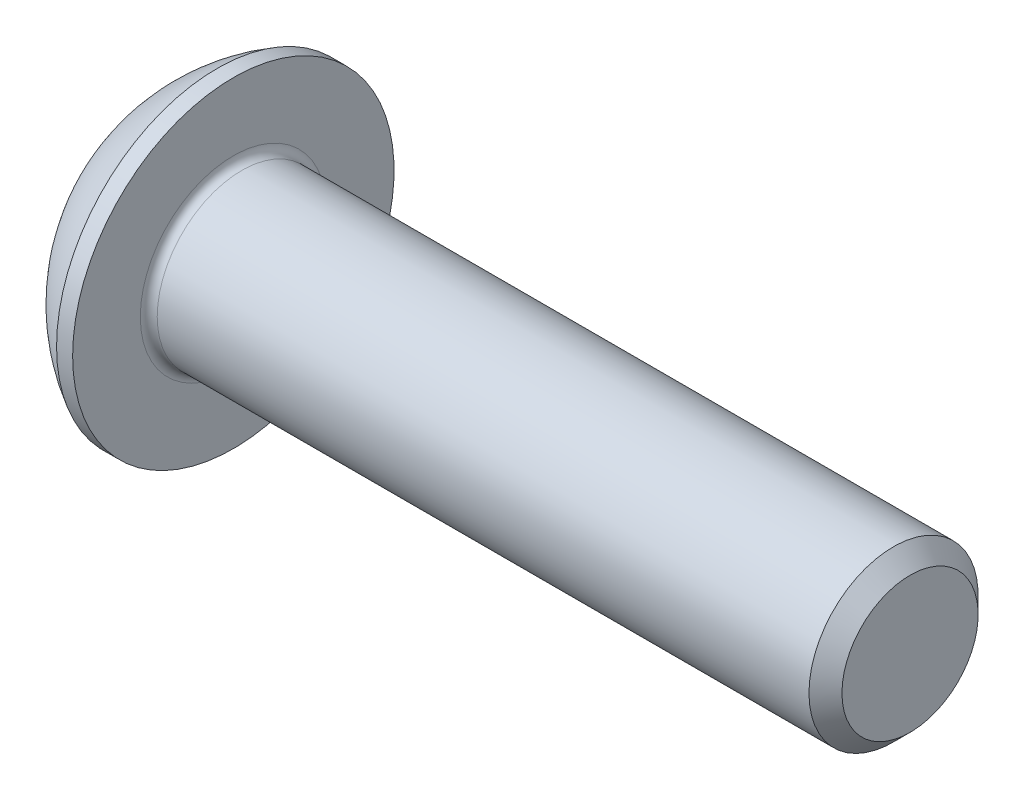
from build123d import *

# Parameters (mm, degrees)
FILLET1_R   = 0.2
HEX_2_DEPTH = 1.3


with BuildPart() as part:
    # BodySke → BaseBody (revolve)
    with BuildSketch(Plane.XY, mode=Mode.PRIVATE) as basebody_sk:
        with BuildLine():
            Line((18.2, 0), (18.2, 1.61))
            Line((18.2, 1.61), (17.81, 2))
            Line((17.81, 2), (2.2, 2))
            Line((2.2, 2), (2.2, 3.8))
            Line((2.2, 3.8), (1.82, 3.8))
            ThreePointArc((1.82, 3.8), (0.762013659, 2.991755338), (0, 1.9))
            Line((0, 1.9), (0, 0))
            Line((0, 0), (18.2, 0))
        make_face()
    revolve(basebody_sk.sketch.rotate(Axis((0, 0, 0), (1, 0, 0)), 90), axis=Axis((0, 0, 0), (1, 0, 0)))  # turned: the seam where the file's is

    # Fillet1
    fillet1_edges = [part.edges().sort_by_distance(p)[0] for p in [
        (2.2, 0, -2),
    ]]
    fillet(fillet1_edges, radius=FILLET1_R)

    # Sketch2 → PreBroach (revolve, cut)
    with BuildSketch(Plane.XY, mode=Mode.PRIVATE) as prebroach_sk:
        Polygon((0, 1.25), (1.3, 1.25), (2.021687836, 0), (0, 0), align=None)
    revolve(prebroach_sk.sketch.rotate(Axis((0, 0, 0), (1, 0, 0)), 90), axis=Axis((0, 0, 0), (1, 0, 0)), mode=Mode.SUBTRACT)  # turned: the seam where the file's is

    # Sketch3 → Hex 2 (cut)
    with BuildSketch(Plane(origin=(0, 0, 0), x_dir=(0, 0, -1), z_dir=(1, 0, 0))):
        Polygon((-1.25, -0.721687836), (-1.25, 0.721687836), (0, 1.443375673), (1.25, 0.721687836), (1.25, -0.721687836), (0, -1.443375673), align=None)
    extrude(amount=HEX_2_DEPTH, mode=Mode.SUBTRACT)


solid = part.part
